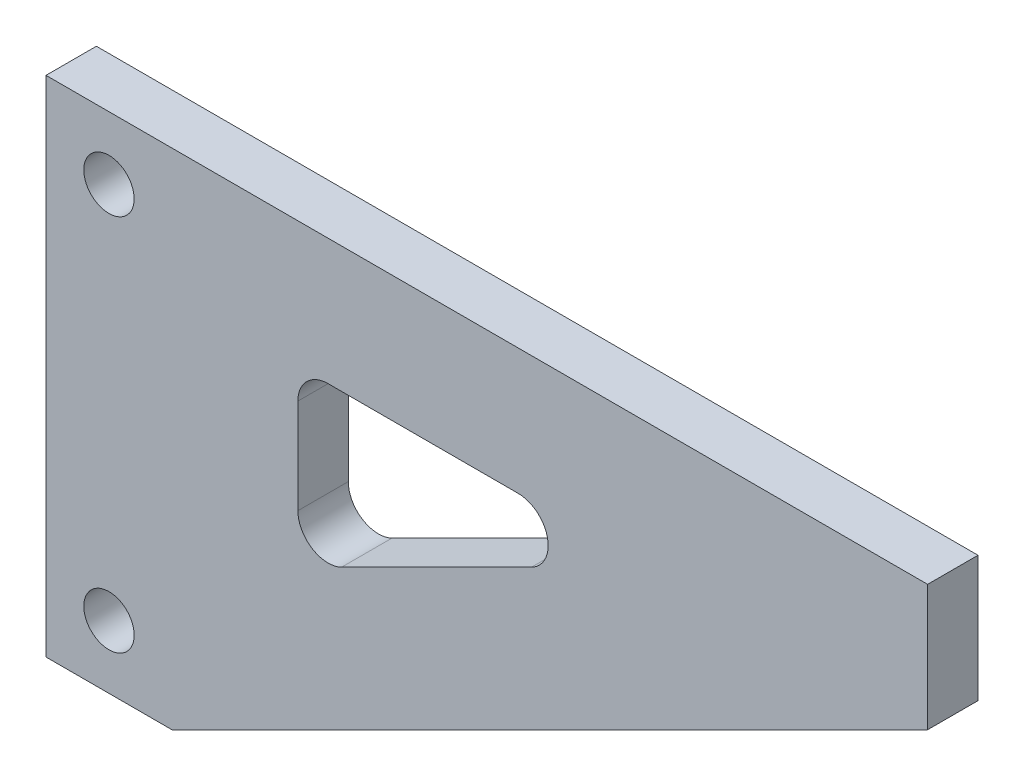
from build123d import *

# Parameters (mm, degrees)
SKETCH1_R          = 5
BASE_EXTRUDE_DEPTH = 10


with BuildPart() as part:
    # Sketch1 → Base-Extrude (new body)
    with BuildSketch(Plane.XY):
        Polygon((0, 0), (25, 0), (175, 75), (175, 100), (0, 100), align=None)
        with Locations((12.5, 12.5)):
            Circle(SKETCH1_R, mode=Mode.SUBTRACT)
        with Locations((12.5, 87.5)):
            Circle(SKETCH1_R, mode=Mode.SUBTRACT)
        with BuildLine():
            Line((50, 50.159053651), (50, 69))
            ThreePointArc((50, 69), (51.757359313, 73.242640687), (56, 75))
            Line((56, 75), (93.681892698, 75))
            ThreePointArc((93.681892698, 75), (99.521386634, 70.378517523), (96.365174271, 63.633436854))
            Line((96.365174271, 63.633436854), (58.683281573, 44.792490505))
            ThreePointArc((58.683281573, 44.792490505), (52.845613327, 45.055148801), (50, 50.159053651))
        make_face(mode=Mode.SUBTRACT)
    extrude(amount=BASE_EXTRUDE_DEPTH)


solid = part.part
